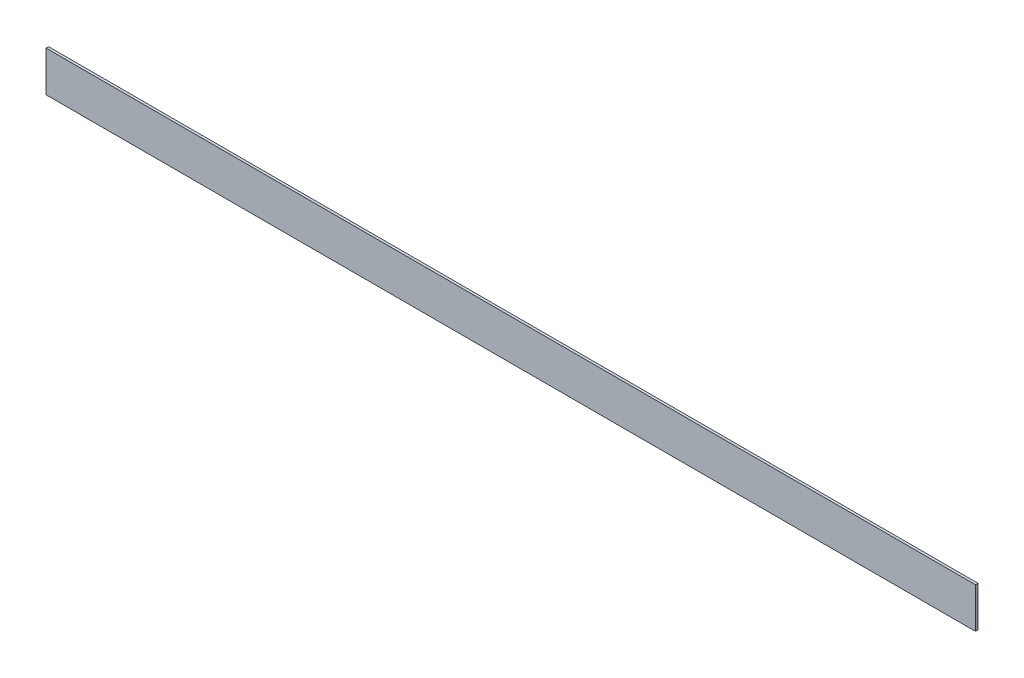
from build123d import *

# Parameters (mm, degrees)
SKETCH1_W           = 584.2
SKETCH1_H           = 25.4
BOSS_EXTRUDE1_DEPTH = 1.5875


with BuildPart() as part:
    # Sketch1 → Boss-Extrude1 (new body)
    with BuildSketch(Plane.XY):
        Rectangle(SKETCH1_W, SKETCH1_H)
    extrude(amount=BOSS_EXTRUDE1_DEPTH)


solid = part.part
